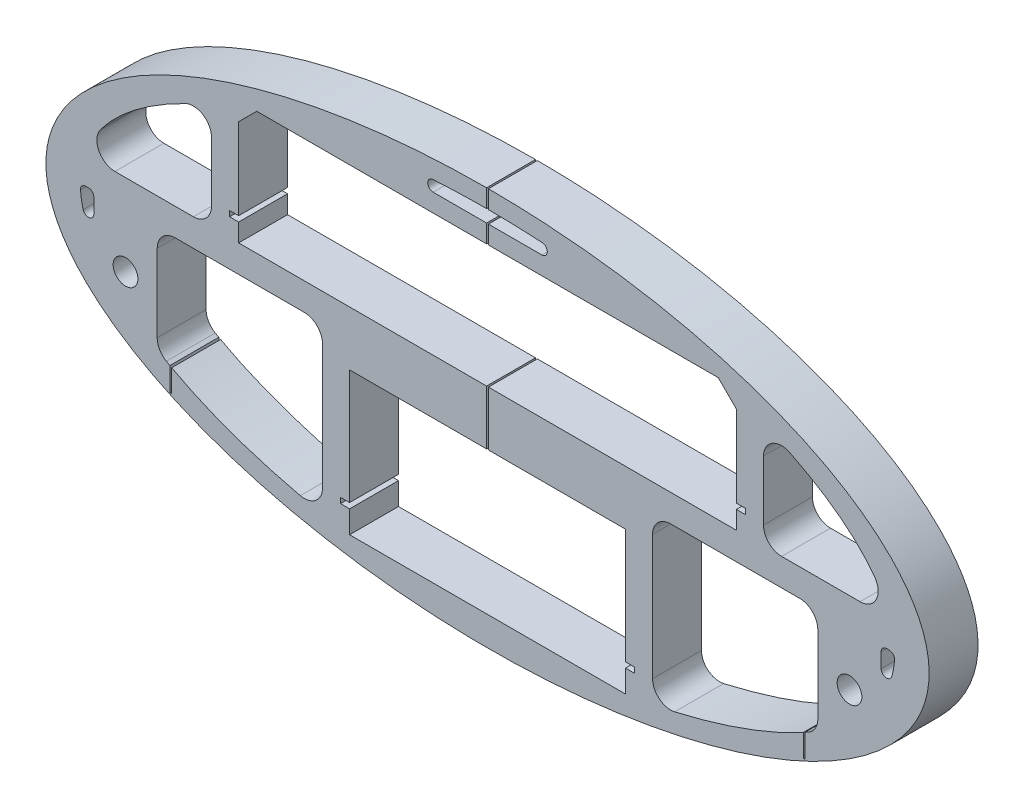
from build123d import *

# Parameters (mm, degrees)
SKETCH1_RX               = 244
SKETCH1_RY               = 110
BOSS_EXTRUDE1_DEPTH      = 27.0275
CUT_EXTRUDE5_DEPTH       = 28.0275
CUT_EXTRUDE7_DEPTH       = 28.0275
SKETCH12_R               = 6.83635542
CUT_EXTRUDE8_DEPTH       = 28.0275
SKETCH14_W               = 1
SKETCH14_H               = 45.520413792
SKETCH14_H_2             = 125
CUT_EXTRUDE9_DEPTH       = 1
CUT_EXTRUDE9_DEPTH_BACK  = 28.0275
CUT_EXTRUDE10_DEPTH      = 1.0000001
CUT_EXTRUDE10_DEPTH_BACK = 28.0275001
FILLET1_R                = 10
FILLET2_R                = 10
FILLET3_R                = 3
FILLET4_R                = 3
CHAMFER1_SIZE            = 10


with BuildPart() as part:
    # Sketch1 → Boss-Extrude1 (new body)
    with BuildSketch(Plane.XY):
        with Locations((0, 0)):
            Ellipse(SKETCH1_RX, SKETCH1_RY)
    extrude(amount=-BOSS_EXTRUDE1_DEPTH)

    # Sketch10 → Cut-Extrude5 (cut, through all)
    with BuildSketch(Plane.XY):
        Polygon((-137.5, 83.1), (137.5, 83.1), (137.5, 28.1), (142.5, 28.1), (142.5, 25.1), (137.5, 25.1), (137.5, 15.1), (-137.5, 15.1), (-137.5, 25.1), (-142.5, 25.1), (-142.5, 28.1), (-137.5, 28.1), align=None)
    extrude(amount=-CUT_EXTRUDE5_DEPTH, mode=Mode.SUBTRACT)

    # Sketch13 → Cut-Extrude7 (cut, through all)
    with BuildSketch(Plane.XY):
        Polygon((-76.2, -81.5), (-76.2, -93.9), (76.2, -93.9), (76.2, -81.5), (81.2, -81.5), (81.2, -78.5), (76.2, -78.5), (76.2, -15), (-76.2, -15), (-76.2, -78.5), (-81.2, -78.5), (-81.2, -81.5), align=None)
    extrude(amount=-CUT_EXTRUDE7_DEPTH, mode=Mode.SUBTRACT)

    # Sketch12 → Cut-Extrude8 (cut, through all)
    with BuildSketch(Plane.XY):
        with Locations((200, -30)):
            Circle(SKETCH12_R)
        with Locations((-200, -30)):
            Circle(SKETCH12_R)
    extrude(amount=-CUT_EXTRUDE8_DEPTH, mode=Mode.SUBTRACT)

    # Sketch14 → Cut-Extrude9 (cut, two sides)
    with BuildSketch(Plane.XY) as cut_extrude9_sk:
        with Locations((175, -52.760206896)):
            Rectangle(SKETCH14_W, SKETCH14_H)
        with Locations((-175, -52.760206896)):
            Rectangle(SKETCH14_W, SKETCH14_H)
        with Locations((0, 47.5)):
            Rectangle(SKETCH14_W, SKETCH14_H_2)
    extrude(amount=CUT_EXTRUDE9_DEPTH, mode=Mode.SUBTRACT)
    extrude(cut_extrude9_sk.sketch, amount=-CUT_EXTRUDE9_DEPTH_BACK, mode=Mode.SUBTRACT)

    # Sketch15 → Cut-Extrude10 (cut, two sides)
    with BuildSketch(Plane.XY) as cut_extrude10_sk:
        with BuildLine():
            Line((152.5, 73.52668114), (152.5, 15.1))
            Line((152.5, 15.1), (222.420096608, 15.1))
            add(Edge.make_bspline(
                [(222.420096608, 15.1), (210.507279325, 49.76143368), (152.5, 73.52668114)],
                knots=[0.151579794, 0.151579794, 0.151579794, 0.826060253, 0.826060253, 0.826060253], degree=2, weights=[1, 0.943671422, 1]))
        make_face()
        with BuildLine():
            Line((91.2, -91.41689608), (91.2, 0))
            Line((91.2, 0), (182.5, 0))
            Line((182.5, 0), (182.5, -58.489209726))
            add(Edge.make_bspline(
                [(91.2, -91.41689608), (146.87726923, -80.44501082), (182.5, -58.489209726)],
                knots=[5.129732411, 5.129732411, 5.129732411, 5.658438287, 5.658438287, 5.658438287], degree=2, weights=[1, 0.96526177, 1]))
        make_face()
        with BuildLine():
            Line((217.5, -25.60381916), (217.5, 0))
            Line((217.5, 0), (225, 0))
            add(Edge.make_bspline(
                [(217.5, -25.60381916), (225, -13.018891098), (225, 0)],
                knots=[6.024263765, 6.024263765, 6.024263765, 6.283185307, 6.283185307, 6.283185307], degree=2, weights=[1, 0.991631652, 1]))
        make_face()
        with BuildLine():
            Line((-82.129314955, 93.1), (82.129314955, 93.1))
            add(Edge.make_bspline(
                [(82.129314955, 93.1), (0, 107.411385607), (-82.129314955, 93.1)],
                knots=[1.197142925, 1.197142925, 1.197142925, 1.944449729, 1.944449729, 1.944449729], degree=2, weights=[1, 0.931, 1]))
        make_face()
        with BuildLine():
            Line((-217.5, 0), (-225, 0))
            add(Edge.make_bspline(
                [(-225, 0), (-225, -13.018891098), (-217.5, -25.60381916)],
                knots=[3.141592654, 3.141592654, 3.141592654, 3.400514196, 3.400514196, 3.400514196], degree=2, weights=[1, 0.991631652, 1]))
            Line((-217.5, -25.60381916), (-217.5, 0))
        make_face()
        with BuildLine():
            Line((-91.2, -91.41689608), (-91.2, 0))
            Line((-91.2, 0), (-182.5, 0))
            Line((-182.5, 0), (-182.5, -58.489209726))
            add(Edge.make_bspline(
                [(-182.5, -58.489209726), (-146.87726923, -80.44501082), (-91.2, -91.41689608)],
                knots=[3.766339674, 3.766339674, 3.766339674, 4.295045549, 4.295045549, 4.295045549], degree=2, weights=[1, 0.96526177, 1]))
        make_face()
        with BuildLine():
            Line((-152.5, 15.1), (-222.420096608, 15.1))
            add(Edge.make_bspline(
                [(-152.5, 73.52668114), (-210.507279325, 49.76143368), (-222.420096608, 15.1)],
                knots=[2.3155324, 2.3155324, 2.3155324, 2.99001286, 2.99001286, 2.99001286], degree=2, weights=[1, 0.943671422, 1]))
            Line((-152.5, 73.52668114), (-152.5, 15.1))
        make_face()
    extrude(amount=CUT_EXTRUDE10_DEPTH, mode=Mode.SUBTRACT)
    extrude(cut_extrude10_sk.sketch, amount=-CUT_EXTRUDE10_DEPTH_BACK, mode=Mode.SUBTRACT)

    # Fillet1
    fillet1_edges = [part.edges().sort_by_distance(p)[0] for p in [
        (222.420096608, 15.1, -13.51375),
        (152.5, 73.52668114, -13.51375),
        (-152.5, 73.52668114, -13.51375),
        (-222.420096608, 15.1, -13.51375),
        (182.5, -58.489209726, -13.51375),
        (-91.2, -91.41689608, -13.51375),
        (-182.5, -58.489209726, -13.51375),
        (91.2, -91.41689608, -13.51375),
    ]]
    fillet(fillet1_edges, radius=FILLET1_R)

    # Fillet2
    fillet2_edges = [part.edges().sort_by_distance(p)[0] for p in [
        (91.2, 0, -13.51375),
        (182.5, 0, -13.51375),
        (-182.5, 0, -13.51375),
        (-91.2, 0, -13.51375),
        (-152.5, 15.1, -13.51375),
        (152.5, 15.1, -13.51375),
    ]]
    fillet(fillet2_edges, radius=FILLET2_R)

    # Fillet3
    fillet3_edges = [part.edges().sort_by_distance(p)[0] for p in [
        (217.5, 0, -13.51375),
        (-217.5, -25.60381916, -13.51375),
        (-225, 0, -13.51375),
        (-217.5, 0, -13.51375),
        (225, 0, -13.51375),
        (217.5, -25.60381916, -13.51375),
    ]]
    fillet(fillet3_edges, radius=FILLET3_R)

    # Fillet4
    fillet4_edges = [part.edges().sort_by_distance(p)[0] for p in [
        (-82.129314955, 93.1, -13.51375),
        (82.129314955, 93.1, -13.51375),
    ]]
    fillet(fillet4_edges, radius=FILLET4_R)

    # Chamfer1
    chamfer1_edges = [part.edges().sort_by_distance(p)[0] for p in [
        (-137.5, 83.1, -13.51375),
        (137.5, 83.1, -13.51375),
    ]]
    chamfer(chamfer1_edges, length=CHAMFER1_SIZE)


solid = part.part
